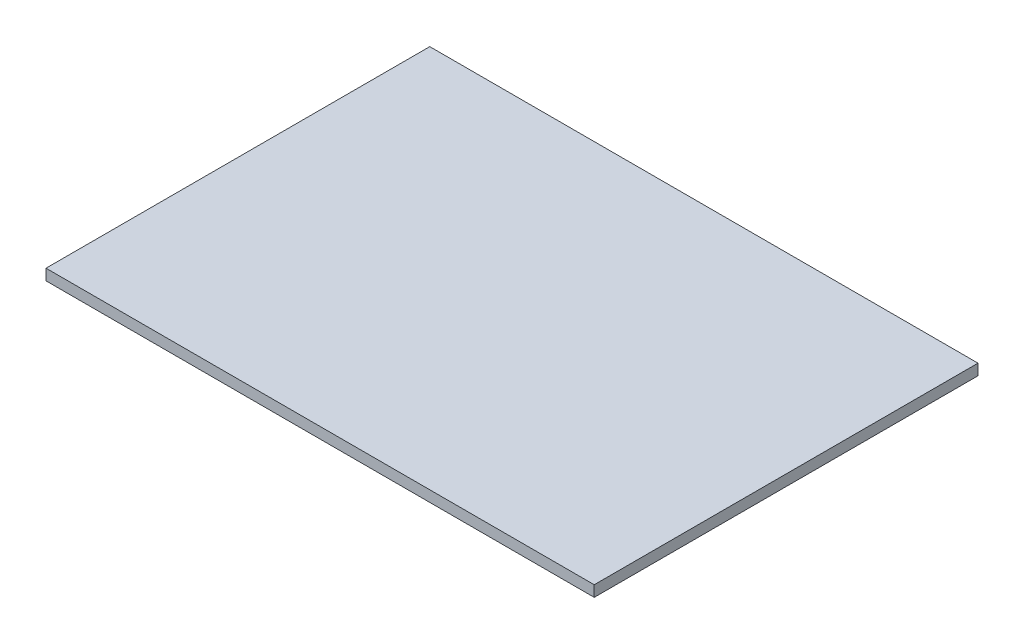
from build123d import *

# Parameters (mm, degrees)
SKICA1_W                = 500
SKICA1_H                = 10
P_IDAT_VYSUNUT_M1_DEPTH = 175


with BuildPart() as part:
    # Skica1 → Přidat vysunutím1 (new body, symmetric)
    with BuildSketch(Plane.XY):
        with Locations((250, -5)):
            Rectangle(SKICA1_W, SKICA1_H)
    extrude(amount=P_IDAT_VYSUNUT_M1_DEPTH, both=True)


solid = part.part
